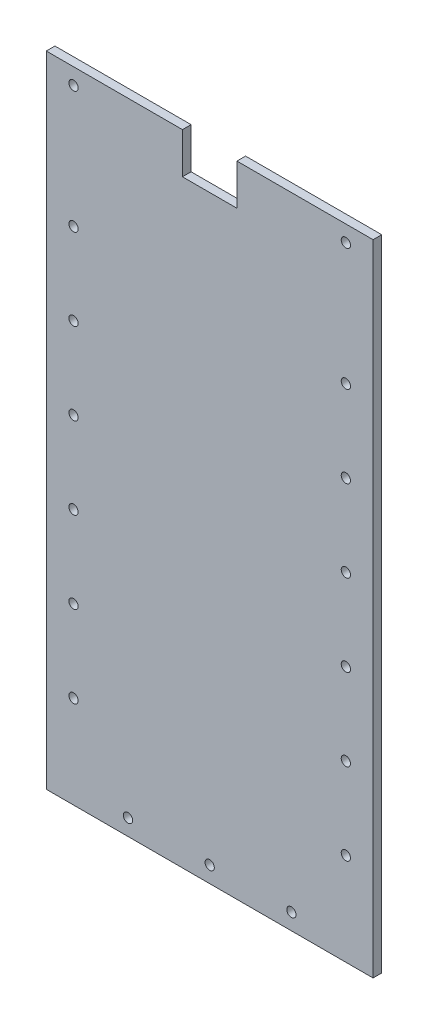
from build123d import *

# Parameters (mm, degrees)
SKETCH1_W                       = 120
SKETCH1_H                       = 234.78
BOSS_EXTRUDE1_DEPTH             = 3.175
CUT_EXTRUDE1_REACH              = 5.175
SKETCH2_W                       = 20
SKETCH2_H                       = 15
TAP_DRILL_FOR_M3X0_5_TAP1_D     = 3.4
TAP_DRILL_FOR_M3X0_5_TAP1_DEPTH = 3.18


with BuildPart() as part:
    # Sketch1 → Boss-Extrude1 (new body)
    with BuildSketch(Plane.XY):
        with Locations((60, 117.39)):
            Rectangle(SKETCH1_W, SKETCH1_H)
    extrude(amount=BOSS_EXTRUDE1_DEPTH)

    # Sketch2 → Cut-Extrude1 (cut, up to next)
    with BuildSketch(Plane.XY.offset(3.175), mode=Mode.PRIVATE) as cut_extrude1_sk1:
        with Locations((60, 227.28)):
            Rectangle(SKETCH2_W, SKETCH2_H)
    cut_extrude1_tool1 = extrude(cut_extrude1_sk1.sketch, amount=-CUT_EXTRUDE1_REACH, mode=Mode.PRIVATE) & part.part
    add(cut_extrude1_tool1.solids().sort_by_distance((60, 227.28, 3.175))[0], mode=Mode.SUBTRACT)

    # Tap Drill for M3x0.5 Tap1
    with Locations(Plane(origin=(42.952239605, 18.521605689, 3.175), x_dir=(-1, 0, 0), z_dir=(0, 0, 1))):
        with Locations((32.952239605, -210.31329226), (32.952239605, -165.478394311), (32.952239605, -105.478394311), (32.952239605, -75.478394311), (32.952239605, -45.478394311), (32.952239605, -15.478394311), (-67.047760395, -210.31329226), (32.952239605, -135.478394311), (12.952239605, 12.57670774), (-17.047760395, 12.57670774), (-47.047760395, 12.57670774), (-67.047760395, -165.478394311), (-67.047760395, -135.478394311), (-67.047760395, -105.478394311), (-67.047760395, -75.478394311), (-67.047760395, -45.478394311), (-67.047760395, -15.478394311)):
            Hole(TAP_DRILL_FOR_M3X0_5_TAP1_D / 2, depth=TAP_DRILL_FOR_M3X0_5_TAP1_DEPTH)


solid = part.part
